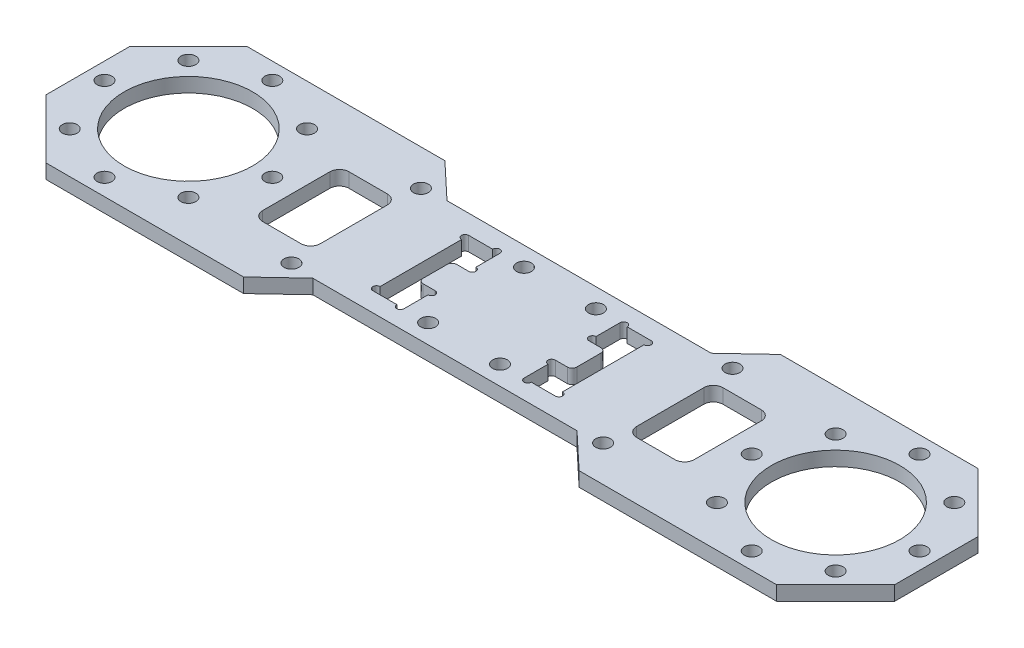
from build123d import *

# Parameters (mm, degrees)
SKETCH_1_W               = 177
SKETCH_1_H               = 42
SKETCH_1_R               = 1.55
SKETCH_1_R_2             = 13.4
EXTRUDE_1_DEPTH          = 1.5
SKETCH_3_W               = 6.5
SKETCH_3_H               = 20
CUT_EXTRUDE_1_DEPTH      = 4
SKETCH_4_W               = 3.5
SKETCH_4_H               = 7
EXTRUDE_2_DEPTH          = 3
SKETCH_5_R               = 0.75
CUT_EXTRUDE_2_DEPTH      = 4
FILLET_1_R               = 1
SKETCH_6_R               = 1.55
CUT_EXTRUDE_3_DEPTH      = 1
CUT_EXTRUDE_3_DEPTH_BACK = 4
CUT_EXTRUDE_4_DEPTH      = 4
SKETCH_8_W               = 12
SKETCH_8_H               = 18
CUT_EXTRUDE_5_DEPTH      = 4
FILLET_2_R               = 2


with BuildPart() as part:
    # 草图1 → 凸台-拉伸1 (new body, symmetric)
    with BuildSketch(Plane(origin=(0, 0, 0), x_dir=(1, 0, 0), z_dir=(0, 1, 0))):
        Rectangle(SKETCH_1_W, SKETCH_1_H)
        with Locations((-67.5, 17.5)):
            Circle(SKETCH_1_R, mode=Mode.SUBTRACT)
        with Locations((-55.125631329, 12.374368671)):
            Circle(SKETCH_1_R, mode=Mode.SUBTRACT)
        with Locations((-50, 0)):
            Circle(SKETCH_1_R, mode=Mode.SUBTRACT)
        with Locations((-55.125631329, -12.374368671)):
            Circle(SKETCH_1_R, mode=Mode.SUBTRACT)
        with Locations((-67.5, -17.5)):
            Circle(SKETCH_1_R, mode=Mode.SUBTRACT)
        with Locations((-79.874368671, -12.374368671)):
            Circle(SKETCH_1_R, mode=Mode.SUBTRACT)
        with Locations((-85, 0)):
            Circle(SKETCH_1_R, mode=Mode.SUBTRACT)
        with Locations((-79.874368671, 12.374368671)):
            Circle(SKETCH_1_R, mode=Mode.SUBTRACT)
        with Locations((67.5, 17.5)):
            Circle(SKETCH_1_R, mode=Mode.SUBTRACT)
        with Locations((55.125631329, 12.374368671)):
            Circle(SKETCH_1_R, mode=Mode.SUBTRACT)
        with Locations((50, 0)):
            Circle(SKETCH_1_R, mode=Mode.SUBTRACT)
        with Locations((55.125631329, -12.374368671)):
            Circle(SKETCH_1_R, mode=Mode.SUBTRACT)
        with Locations((67.5, -17.5)):
            Circle(SKETCH_1_R, mode=Mode.SUBTRACT)
        with Locations((79.874368671, -12.374368671)):
            Circle(SKETCH_1_R, mode=Mode.SUBTRACT)
        with Locations((85, 0)):
            Circle(SKETCH_1_R, mode=Mode.SUBTRACT)
        with Locations((79.874368671, 12.374368671)):
            Circle(SKETCH_1_R, mode=Mode.SUBTRACT)
        with Locations((-67.5, 0)):
            Circle(SKETCH_1_R_2, mode=Mode.SUBTRACT)
        with Locations((67.5, 0)):
            Circle(SKETCH_1_R_2, mode=Mode.SUBTRACT)
    extrude(amount=EXTRUDE_1_DEPTH, both=True)

    # 草图3 → 切除-拉伸1 (cut, through all)
    with BuildSketch(Plane(origin=(0, 1.5, 0), x_dir=(1, 0, 0), z_dir=(0, 1, 0))):
        with Locations((15.775, 0)):
            Rectangle(SKETCH_3_W, SKETCH_3_H)
        with Locations((-15.775, 0)):
            Rectangle(SKETCH_3_W, SKETCH_3_H)
    extrude(amount=-CUT_EXTRUDE_1_DEPTH, mode=Mode.SUBTRACT)

    # 草图4 → 凸台-拉伸2 (add)
    with BuildSketch(Plane(origin=(0, 1.5, 0), x_dir=(1, 0, 0), z_dir=(0, 1, 0))):
        with Locations((-14.275, 0)):
            Rectangle(SKETCH_4_W, SKETCH_4_H)
        with Locations((14.275, 0)):
            Rectangle(SKETCH_4_W, SKETCH_4_H)
    extrude(amount=-EXTRUDE_2_DEPTH)

    # 草图5 → 切除-拉伸2 (cut, through all)
    with BuildSketch(Plane(origin=(0, 1.5, 0), x_dir=(1, 0, 0), z_dir=(0, 1, 0))):
        with Locations((12.525, 4.25)):
            Circle(SKETCH_5_R)
        with Locations((12.525, -4.25)):
            Circle(SKETCH_5_R)
        with Locations((13.275, -10)):
            Circle(SKETCH_5_R)
        with Locations((13.275, 10)):
            Circle(SKETCH_5_R)
        with Locations((19.025, 9.25)):
            Circle(SKETCH_5_R)
        with Locations((19.025, -9.25)):
            Circle(SKETCH_5_R)
        with Locations((-19.025, -9.25)):
            Circle(SKETCH_5_R)
        with Locations((-19.025, 9.25)):
            Circle(SKETCH_5_R)
        with Locations((-13.275, 10)):
            Circle(SKETCH_5_R)
        with Locations((-13.275, -10)):
            Circle(SKETCH_5_R)
        with Locations((-12.525, -4.25)):
            Circle(SKETCH_5_R)
        with Locations((-12.525, 4.25)):
            Circle(SKETCH_5_R)
    extrude(amount=-CUT_EXTRUDE_2_DEPTH, mode=Mode.SUBTRACT)

    # 圆角1
    fillet_1_edges = [part.edges().sort_by_distance(p)[0] for p in [
        (-16.025, 0, 3.5),
        (-16.025, 0, -3.5),
        (16.025, 0, -3.5),
        (16.025, 0, 3.5),
    ]]
    fillet(fillet_1_edges, radius=FILLET_1_R)

    # 草图6 → 切除-拉伸3 (cut, two sides)
    with BuildSketch(Plane(origin=(0, 1.5, 0), x_dir=(1, 0, 0), z_dir=(0, 1, 0))) as cut_extrude_3_sk:
        with Locations((-32.5, 13.5)):
            Circle(SKETCH_6_R)
        with Locations((-32.5, -13.5)):
            Circle(SKETCH_6_R)
        with Locations((-7.5, 10)):
            Circle(SKETCH_6_R)
        with Locations((-7.5, -10)):
            Circle(SKETCH_6_R)
        with Locations((7.5, -10)):
            Circle(SKETCH_6_R)
        with Locations((7.5, 10)):
            Circle(SKETCH_6_R)
        with Locations((32.5, 13.5)):
            Circle(SKETCH_6_R)
        with Locations((32.5, -13.5)):
            Circle(SKETCH_6_R)
    extrude(amount=CUT_EXTRUDE_3_DEPTH, mode=Mode.SUBTRACT)
    extrude(cut_extrude_3_sk.sketch, amount=-CUT_EXTRUDE_3_DEPTH_BACK, mode=Mode.SUBTRACT)

    # 草图7 → 切除-拉伸4 (cut, through all)
    with BuildSketch(Plane.XZ.offset(1.5)):
        Polygon((-35, 21), (-27.558405496, 14), (27.558405496, 14), (35, 21), align=None)
        Polygon((-88.5, 8.69848481), (-76.19848481, 21), (-88.5, 21), align=None)
        Polygon((76.19848481, 21), (88.5, 21), (88.5, 8.69848481), align=None)
    cut_extrude_4 = extrude(amount=-CUT_EXTRUDE_4_DEPTH, mode=Mode.SUBTRACT)

    # 镜向1: 切除-拉伸4 across plane
    add(cut_extrude_4.mirror(Plane.XY), mode=Mode.SUBTRACT)

    # 草图8 → 切除-拉伸5 (cut, through all)
    with BuildSketch(Plane.XZ.offset(1.5)):
        with Locations((-39, 0)):
            Rectangle(SKETCH_8_W, SKETCH_8_H)
        with Locations((39, 0)):
            Rectangle(SKETCH_8_W, SKETCH_8_H)
    extrude(amount=-CUT_EXTRUDE_5_DEPTH, mode=Mode.SUBTRACT)

    # 圆角2
    fillet_2_edges = [part.edges().sort_by_distance(p)[0] for p in [
        (-45, 0, -9),
        (-45, 0, 9),
        (-33, 0, 9),
        (-33, 0, -9),
        (33, 0, -9),
        (33, 0, 9),
        (45, 0, 9),
        (45, 0, -9),
    ]]
    fillet(fillet_2_edges, radius=FILLET_2_R)


solid = part.part
